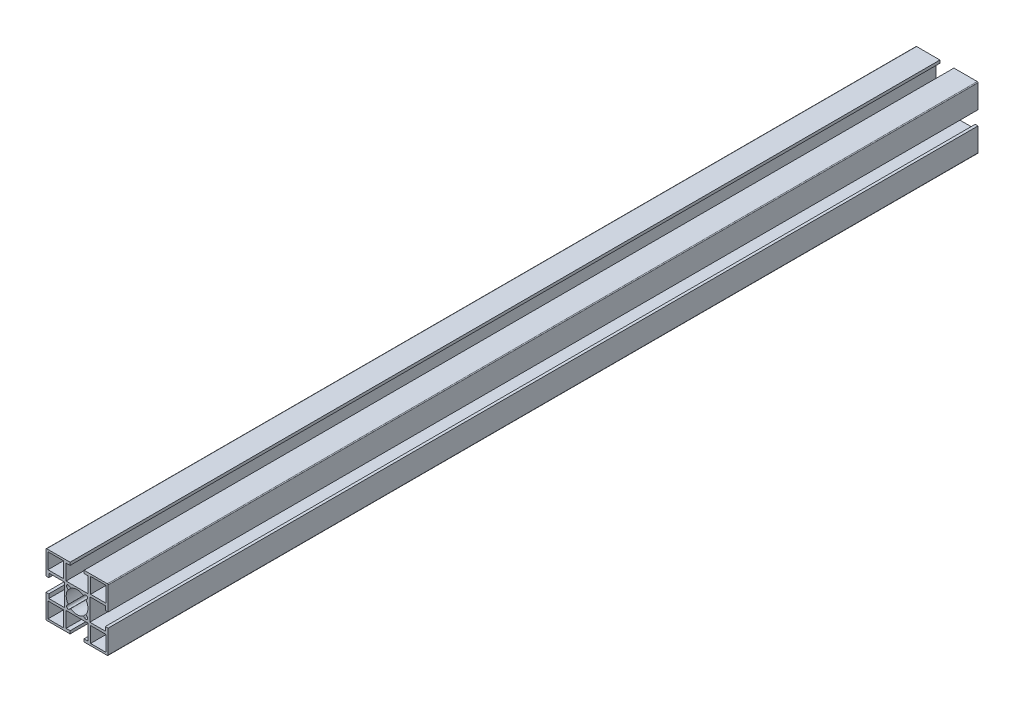
from build123d import *

# Parameters (mm, degrees)
SKETCH1_W                 = 10
SKETCH1_H                 = 10
F_40_X_40A_X_R0_5_1_DEPTH = 560


with BuildPart() as part:
    # Sketch1 → 铝型材 40 X 40A X R0.5(1) (new body)
    with BuildSketch(Plane.YX):
        with BuildLine():
            Line((-19.5, 20), (-4.5, 20))
            Line((-4.5, 20), (-4.5, 18.2))
            Line((-4.5, 18.2), (-7.1, 18.2))
            Line((-7.1, 18.2), (-7.1, 8.2))
            Line((-7.1, 8.2), (7.1, 8.2))
            Line((7.1, 8.2), (7.1, 18.2))
            Line((7.1, 18.2), (4.5, 18.2))
            Line((4.5, 18.2), (4.5, 20))
            Line((4.5, 20), (19.5, 20))
            ThreePointArc((19.5, 20), (19.853553391, 19.853553391), (20, 19.5))
            Line((20, 19.5), (20, 4.5))
            Line((20, 4.5), (18.2, 4.5))
            Line((18.2, 4.5), (18.2, 7.1))
            Line((18.2, 7.1), (8.2, 7.1))
            Line((8.2, 7.1), (8.2, -7.1))
            Line((8.2, -7.1), (18.2, -7.1))
            Line((18.2, -7.1), (18.2, -4.5))
            Line((18.2, -4.5), (20, -4.5))
            Line((20, -4.5), (20, -19.5))
            ThreePointArc((20, -19.5), (19.853553391, -19.853553391), (19.5, -20))
            Line((19.5, -20), (4.5, -20))
            Line((4.5, -20), (4.5, -18.2))
            Line((4.5, -18.2), (7.1, -18.2))
            Line((7.1, -18.2), (7.1, -8.2))
            Line((7.1, -8.2), (-7.1, -8.2))
            Line((-7.1, -8.2), (-7.1, -18.2))
            Line((-7.1, -18.2), (-4.5, -18.2))
            Line((-4.5, -18.2), (-4.5, -20))
            Line((-4.5, -20), (-19.5, -20))
            ThreePointArc((-19.5, -20), (-19.853553391, -19.853553391), (-20, -19.5))
            Line((-20, -19.5), (-20, -4.5))
            Line((-20, -4.5), (-18.2, -4.5))
            Line((-18.2, -4.5), (-18.2, -7.1))
            Line((-18.2, -7.1), (-8.2, -7.1))
            Line((-8.2, -7.1), (-8.2, 7.1))
            Line((-8.2, 7.1), (-18.2, 7.1))
            Line((-18.2, 7.1), (-18.2, 4.5))
            Line((-18.2, 4.5), (-20, 4.5))
            Line((-20, 4.5), (-20, 19.5))
            ThreePointArc((-20, 19.5), (-19.853553391, 19.853553391), (-19.5, 20))
        make_face()
        with BuildLine():
            Line((-4.87903679, 6.434671709), (-4.110433762, 5.66606868))
            ThreePointArc((-4.110433762, 5.66606868), (0, 7), (4.110433762, 5.66606868))
            Line((4.110433762, 5.66606868), (4.87903679, 6.434671709))
            ThreePointArc((4.87903679, 6.434671709), (6.434671709, 6.434671709), (6.434671709, 4.87903679))
            Line((6.434671709, 4.87903679), (5.66606868, 4.110433762))
            ThreePointArc((5.66606868, 4.110433762), (7, 0), (5.66606868, -4.110433762))
            Line((5.66606868, -4.110433762), (6.434671709, -4.87903679))
            ThreePointArc((6.434671709, -4.87903679), (6.434671709, -6.434671709), (4.87903679, -6.434671709))
            Line((4.87903679, -6.434671709), (4.110433762, -5.66606868))
            ThreePointArc((4.110433762, -5.66606868), (0, -7), (-4.110433762, -5.66606868))
            Line((-4.110433762, -5.66606868), (-4.87903679, -6.434671709))
            ThreePointArc((-4.87903679, -6.434671709), (-6.434671709, -6.434671709), (-6.434671709, -4.87903679))
            Line((-6.434671709, -4.87903679), (-5.66606868, -4.110433762))
            ThreePointArc((-5.66606868, -4.110433762), (-7, 0), (-5.66606868, 4.110433762))
            Line((-5.66606868, 4.110433762), (-6.434671709, 4.87903679))
            ThreePointArc((-6.434671709, 4.87903679), (-6.434671709, 6.434671709), (-4.87903679, 6.434671709))
        make_face(mode=Mode.SUBTRACT)
        with Locations((-13.7, 13.7)):
            Rectangle(SKETCH1_W, SKETCH1_H, mode=Mode.SUBTRACT)
        with Locations((13.7, 13.7)):
            Rectangle(SKETCH1_W, SKETCH1_H, mode=Mode.SUBTRACT)
        with Locations((13.7, -13.7)):
            Rectangle(SKETCH1_W, SKETCH1_H, mode=Mode.SUBTRACT)
        with Locations((-13.7, -13.7)):
            Rectangle(SKETCH1_W, SKETCH1_H, mode=Mode.SUBTRACT)
    extrude(amount=F_40_X_40A_X_R0_5_1_DEPTH)


solid = part.part
